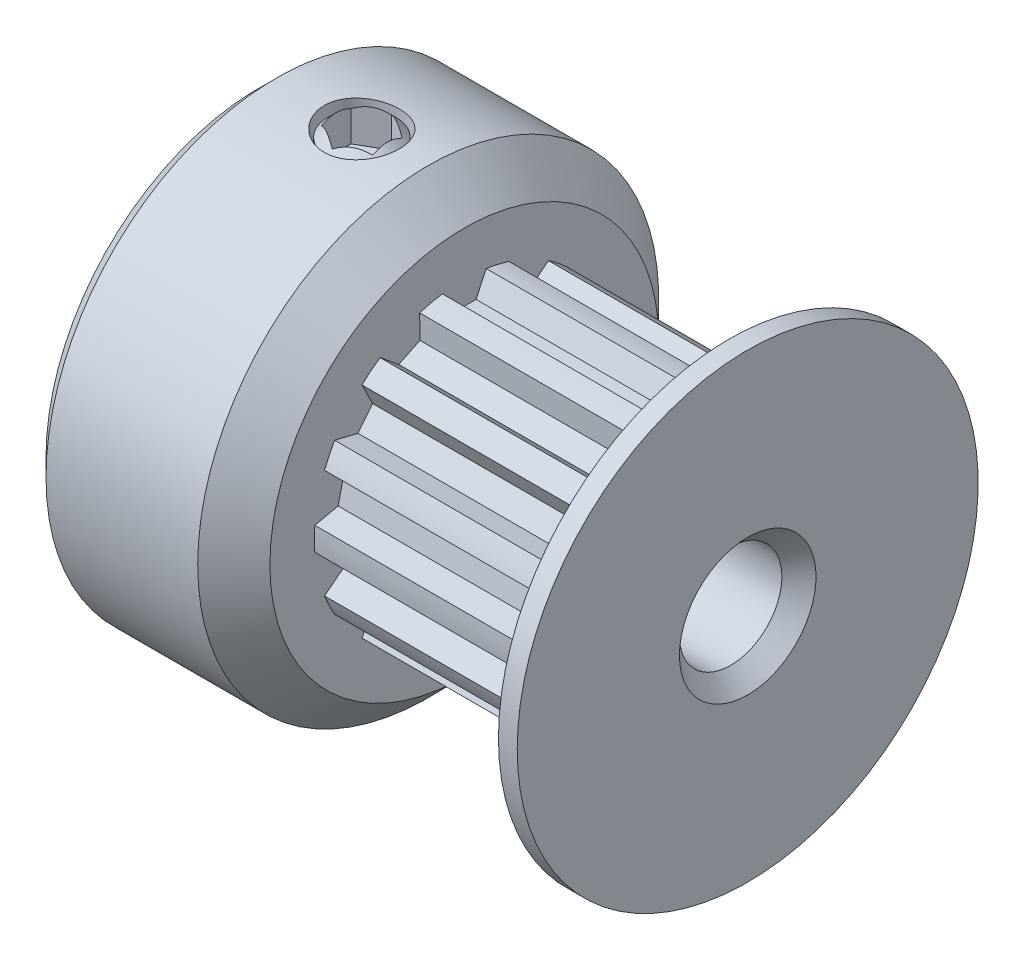
from build123d import *

# Parameters (mm, degrees)
SKETCH4_R          = 4.55
SKETCH4_R_2        = 4.39125
CUT_EXTRUDE2_DEPTH = 7.2
CUT_EXTRUDE1_DEPTH = 7.2
CIRPATTERN1_COUNT  = 14
SKETCH6_R          = 1.1
CUT_EXTRUDE3_DEPTH = 12.926755636
CUT_EXTRUDE4_DEPTH = 1.016
CHAMFER1_SIZE      = 0.5


with BuildPart() as part:
    # Sketch1 → Revolve1 (revolve)
    with BuildSketch(Plane.XY, mode=Mode.PRIVATE) as revolve1_sk:
        with BuildLine():
            Line((-7.15, 1.5), (7.15, 1.5))
            Line((7.15, 1.5), (7.15, 6.75))
            Line((7.15, 6.75), (6.6, 6.75))
            ThreePointArc((6.6, 6.75), (6.191212109, 5.980934734), (6.05, 5.1215))
            Line((6.05, 5.1215), (6.05, 4.55))
            Line((6.05, 4.55), (-1.15, 4.55))
            Line((-1.15, 4.55), (-1.15, 5.693))
            Line((-1.15, 5.693), (-2.207, 6.75))
            Line((-2.207, 6.75), (-7.15, 6.75))
            Line((-7.15, 6.75), (-7.15, 1.5))
        make_face()
    revolve(revolve1_sk.sketch.rotate(Axis((-7.15, 0, 0), (1, 0, 0)), 90), axis=Axis((-7.15, 0, 0), (1, 0, 0)))

    # Sketch4 → Cut-Extrude2 (cut)
    with BuildSketch(Plane(origin=(-1.15, 0, 0), x_dir=(0, 0, -1), z_dir=(1, 0, 0))):
        Circle(SKETCH4_R)
        Circle(SKETCH4_R_2, mode=Mode.SUBTRACT)
    extrude(amount=CUT_EXTRUDE2_DEPTH, mode=Mode.SUBTRACT)

    # Sketch3 → Cut-Extrude1 (cut)
    with BuildSketch(Plane(origin=(-1.15, 0, 0), x_dir=(0, 0, -1), z_dir=(1, 0, 0))):
        with BuildLine():
            Line((-0.641624805, 4.344121795), (-0.345214105, 3.708466998))
            Line((-0.345214105, 3.708466998), (0.345214105, 3.708466998))
            Line((0.345214105, 3.708466998), (0.641624805, 4.344121795))
            ThreePointArc((0.641624805, 4.344121795), (0, 4.39125), (-0.641624805, 4.344121795))
        make_face()
    cut_extrude1 = extrude(amount=CUT_EXTRUDE1_DEPTH, mode=Mode.SUBTRACT)

    # CirPattern1: Cut-Extrude1 ×14 about axis
    cirpattern1_axis = Axis((0, 0, 0), (1, 0, 0))
    for i in range(1, CIRPATTERN1_COUNT):
        add(cut_extrude1.rotate(cirpattern1_axis, i * 360 / CIRPATTERN1_COUNT), mode=Mode.SUBTRACT)

    # Sketch6 → Cut-Extrude3 (cut, through all)
    with BuildSketch(Plane(origin=(0, 0, 0), x_dir=(1, 0, 0), z_dir=(0, 1, 0))):
        with Locations(Location((-4.15, 0, 0), (0, 0, 90))):
            Circle(SKETCH6_R)
    extrude(amount=CUT_EXTRUDE3_DEPTH, mode=Mode.SUBTRACT)

    # Chamfer1
    chamfer1_edges = [part.edges().sort_by_distance(p)[0] for p in [
        (-7.15, 0, -6.75),
        (-7.15, 0, -1.5),
        (7.15, 0, -1.5),
    ]]
    chamfer(chamfer1_edges, length=CHAMFER1_SIZE)


with BuildPart() as body_2:
    # Sketch7 → Revolve2 (revolve)
    with BuildSketch(Plane.XY, mode=Mode.PRIVATE) as revolve2_sk:
        Polygon((-4.896, 6.75), (-4.15, 6.75), (-4.15, 1.881), (-4.896, 1.881), (-5.15, 2.135), (-5.15, 6.496), align=None)
    revolve(revolve2_sk.sketch.rotate(Axis((-4.15, 1.881, 0), (0, 1, 0)), 270), axis=Axis((-4.15, 1.881, 0), (0, 1, 0)))

    # Sketch8 → Cut-Extrude4 (cut)
    with BuildSketch(Plane(origin=(0, 6.75, 0), x_dir=(1, 0, 0), z_dir=(0, 1, 0))):
        Polygon((-4.15, 0.866025404), (-4.9, 0.433012702), (-4.9, -0.433012702), (-4.15, -0.866025404), (-3.4, -0.433012702), (-3.4, 0.433012702), align=None)
    extrude(amount=-CUT_EXTRUDE4_DEPTH, mode=Mode.SUBTRACT)


solid = Compound([part.part, body_2.part])
